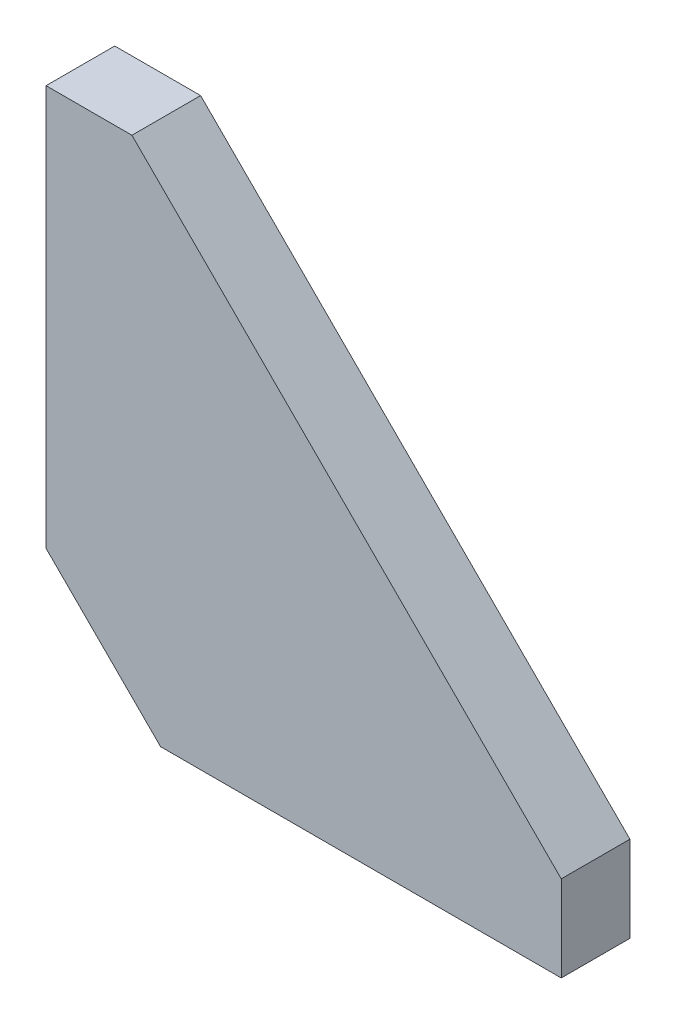
from build123d import *

# Parameters (mm, degrees)
BOSS_EXTRUDE1_DEPTH = 12


with BuildPart() as part:
    # Sketch1 → Boss-Extrude1 (new body)
    with BuildSketch(Plane.XY):
        Polygon((-20, 20), (-20, 90), (-5, 90), (70, 15), (70, 0), (0, 0), align=None)
    extrude(amount=BOSS_EXTRUDE1_DEPTH)


solid = part.part
